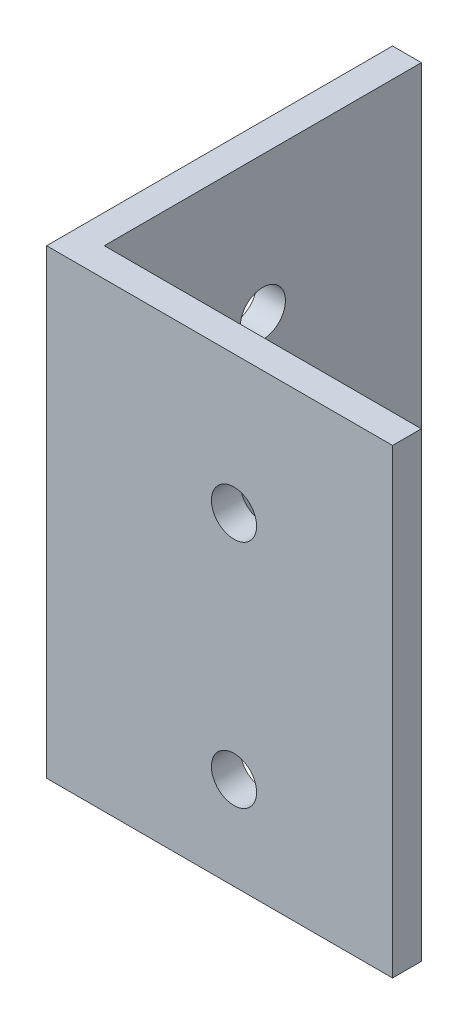
from build123d import *

# Parameters (mm, degrees)
EXTRUDE_THIN1_DEPTH = 25.4
SKETCH2_R           = 2.4892
CUT_EXTRUDE1_DEPTH  = 4.175


with BuildPart() as part:
    # Sketch1 → Extrude-Thin1 (new body, symmetric)
    with BuildSketch(Plane(origin=(0, 0, 0), x_dir=(1, 0, 0), z_dir=(0, 1, 0))):
        Polygon((0, 38.1), (0, 0), (38.1, 0), (38.1, 3.175), (3.175, 3.175), (3.175, 38.1), align=None)
    extrude(amount=EXTRUDE_THIN1_DEPTH, both=True)

    # Sketch2 → Cut-Extrude1 (cut, through all)
    with BuildSketch(Plane(origin=(0, 0, -3.175), x_dir=(-1, 0, 0), z_dir=(0, 0, -1))):
        with Locations((-20.6375, 10.2108)):
            Circle(SKETCH2_R)
        with Locations((-20.6375, -15.1892)):
            Circle(SKETCH2_R)
    cut_extrude1 = extrude(amount=-CUT_EXTRUDE1_DEPTH, mode=Mode.SUBTRACT)

    # Mirror1: Cut-Extrude1 across plane
    add(cut_extrude1.mirror(Plane(origin=(0, 0, 0), x_dir=(-0.707106781, 0, 0.707106781), z_dir=(-0.707106781, 0, -0.707106781))), mode=Mode.SUBTRACT)


solid = part.part
